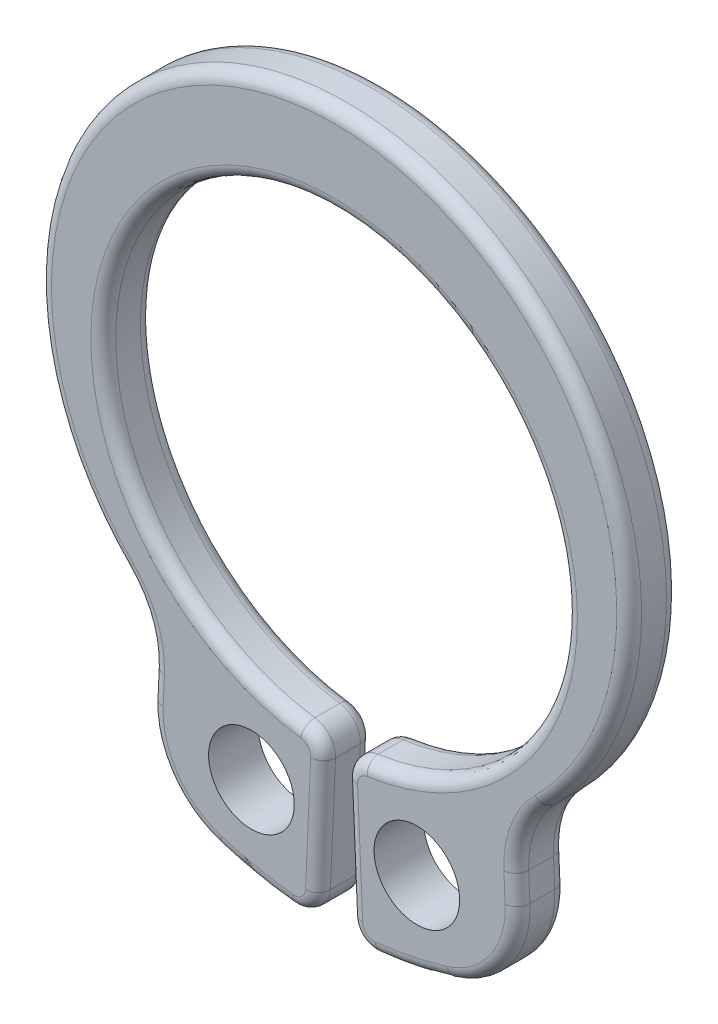
from build123d import *

# Parameters (mm, degrees)
SKETCH2_R           = 0.8625
BOSS_EXTRUDE1_DEPTH = 0.5
FILLET1_R           = 1.921041991
FILLET2_R           = 0.480260498
FILLET3_R           = 0.25


with BuildPart() as part:
    # Sketch2 → Boss-Extrude1 (new, symmetric)
    with BuildSketch(Plane.XY):
        with BuildLine():
            Line((-3.754304556, -7.016279558), (-3.627139009, -4.200757385))
            ThreePointArc((-3.627139009, -4.200757385), (-5.625717071, 2.422856602), (0, 6.45))
            Line((0, 6.45), (0, 4.65))
            ThreePointArc((0, 4.65), (-4.648893426, 0.101439215), (-0.202830151, -4.64557423))
            Line((-0.202830151, -4.64557423), (-0.347104496, -7.95))
            ThreePointArc((-0.347104496, -7.95), (-2.10317558, -7.674609698), (-3.754304556, -7.016279558))
        make_face()
        with Locations((-1.666082021, -6.079629946)):
            Circle(SKETCH2_R, mode=Mode.SUBTRACT)
    extrude(amount=BOSS_EXTRUDE1_DEPTH, both=True)

    # Fillet1
    fillet1_edges = [part.edges().sort_by_distance(p)[0] for p in [
        (-3.754304556, -7.016279558, 0),
        (-3.627139009, -4.200757385, 0),
    ]]
    fillet(fillet1_edges, radius=FILLET1_R)

    # Fillet2
    fillet2_edges = [part.edges().sort_by_distance(p)[0] for p in [
        (-0.202830151, -4.64557423, 0),
        (-0.347104496, -7.95, 0),
    ]]
    fillet(fillet2_edges, radius=FILLET2_R)

    # Mirror1: part across plane


with BuildPart() as part_1:
    add(part.part)
    add(part.part.mirror(Plane(origin=(0, 6.45, 0.5), x_dir=(0, 0, 1), z_dir=(-1, 0, 0))))

    # Fillet3
    fillet3_edges = [part_1.edges().sort_by_distance(p)[0] for p in [
        (-1.605720807, -7.793884925, -0.5),
        (-1.605720807, -7.793884925, 0.5),
        (-3.681225059, -5.398255259, -0.5),
        (-3.345602294, -6.875839317, -0.5),
        (-3.681225059, -5.398255259, 0.5),
        (-3.345602294, -6.875839317, 0.5),
        (-3.794832075, -4.336244669, -0.5),
        (-3.794832075, -4.336244669, 0.5),
        (-0.274139251, -6.278821126, -0.5),
        (-0.274139251, -6.278821126, 0.5),
        (0, 4.65, -0.5),
        (-0.333699735, -4.774410428, -0.5),
        (-0.492371159, -7.798150947, -0.5),
        (4.639033625, 0.319166148, 0.5),
        (-0.333699735, -4.774410428, 0.5),
        (5.48511353, 2.794516832, 0.5),
        (-0.492371159, -7.798150947, 0.5),
        (0.274139251, -6.278821126, -0.5),
        (3.681225059, -5.398255259, -0.5),
        (1.605720807, -7.793884925, -0.5),
        (3.681225059, -5.398255259, 0.5),
        (1.605720807, -7.793884925, 0.5),
        (0.274139251, -6.278821126, 0.5),
        (3.345602294, -6.875839317, 0.5),
        (3.345602294, -6.875839317, -0.5),
        (3.794832075, -4.336244669, 0.5),
        (3.794832075, -4.336244669, -0.5),
        (0.492371159, -7.798150947, 0.5),
        (0.492371159, -7.798150947, -0.5),
        (0.333699735, -4.774410428, 0.5),
        (0.333699735, -4.774410428, -0.5),
        (5.48511353, 2.794516832, -0.5),
    ]]
    fillet(fillet3_edges, radius=FILLET3_R)


solid = part_1.part
